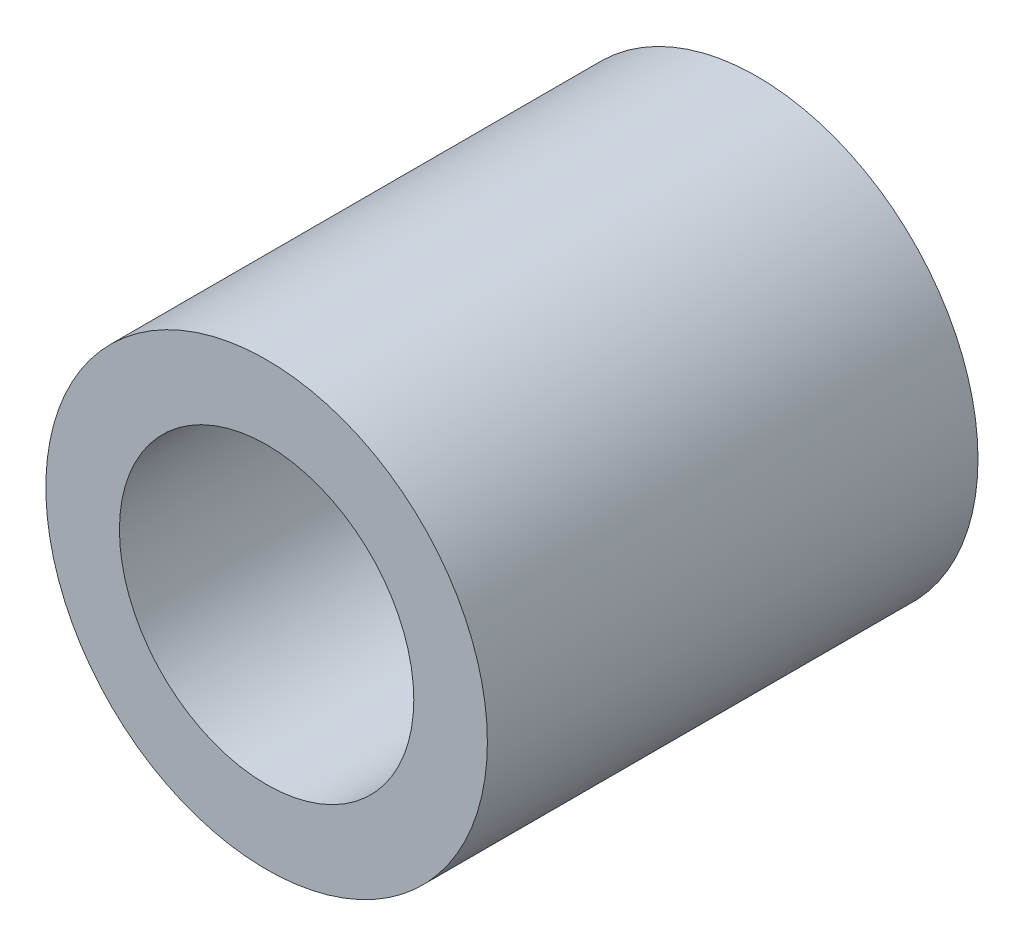
from build123d import *

# Parameters (mm, degrees)
SKETCH1_R           = 4.5
SKETCH1_R_2         = 3
BOSS_EXTRUDE1_DEPTH = 10


with BuildPart() as part:
    # Sketch1 → Boss-Extrude1 (new body)
    with BuildSketch(Plane.XY):
        Circle(SKETCH1_R)
        Circle(SKETCH1_R_2, mode=Mode.SUBTRACT)
    extrude(amount=BOSS_EXTRUDE1_DEPTH)


solid = part.part
